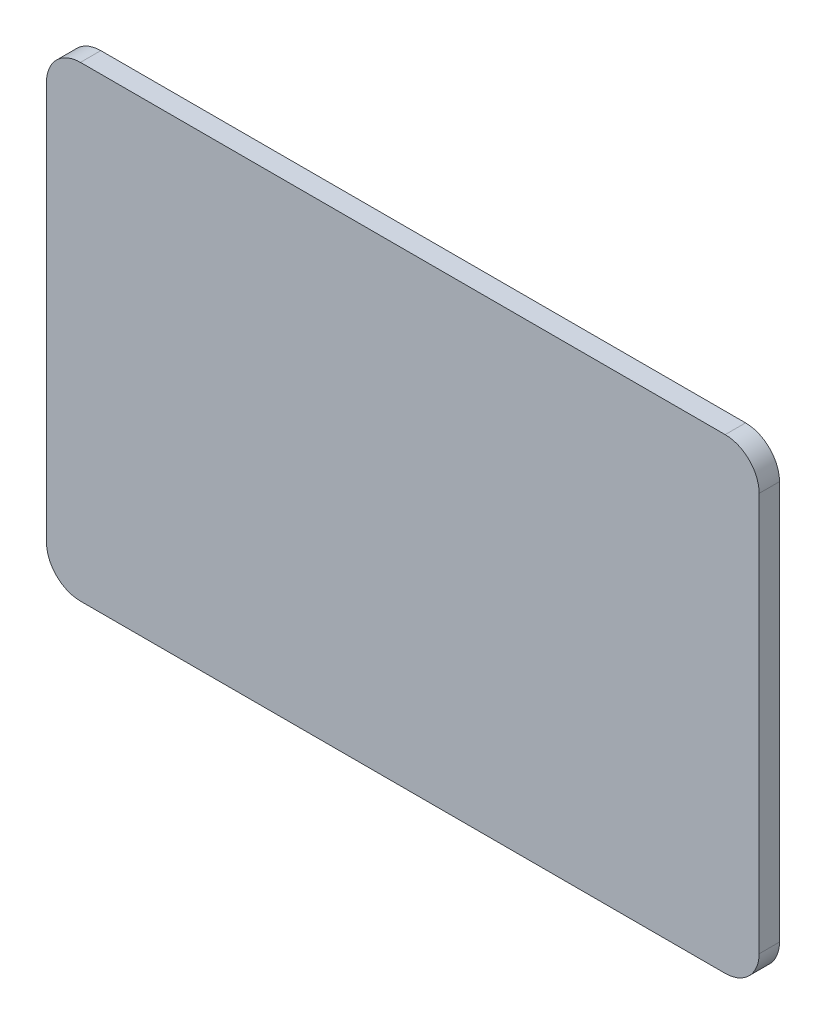
from build123d import *

# Parameters (mm, degrees)
BOSS_EXTRUDE1_DEPTH = 3


with BuildPart() as part:
    # Sketch1 → Boss-Extrude1 (new body)
    with BuildSketch(Plane.XY):
        with BuildLine():
            Line((47.5, -34.375), (-47.5, -34.375))
            ThreePointArc((-47.5, -34.375), (-51.035533906, -32.910533906), (-52.5, -29.375))
            Line((-52.5, -29.375), (-52.5, 29.375))
            ThreePointArc((-52.5, 29.375), (-51.035533906, 32.910533906), (-47.5, 34.375))
            Line((-47.5, 34.375), (47.5, 34.375))
            ThreePointArc((47.5, 34.375), (51.035533906, 32.910533906), (52.5, 29.375))
            Line((52.5, 29.375), (52.5, -29.375))
            ThreePointArc((52.5, -29.375), (51.035533906, -32.910533906), (47.5, -34.375))
        make_face()
    extrude(amount=BOSS_EXTRUDE1_DEPTH)


solid = part.part
